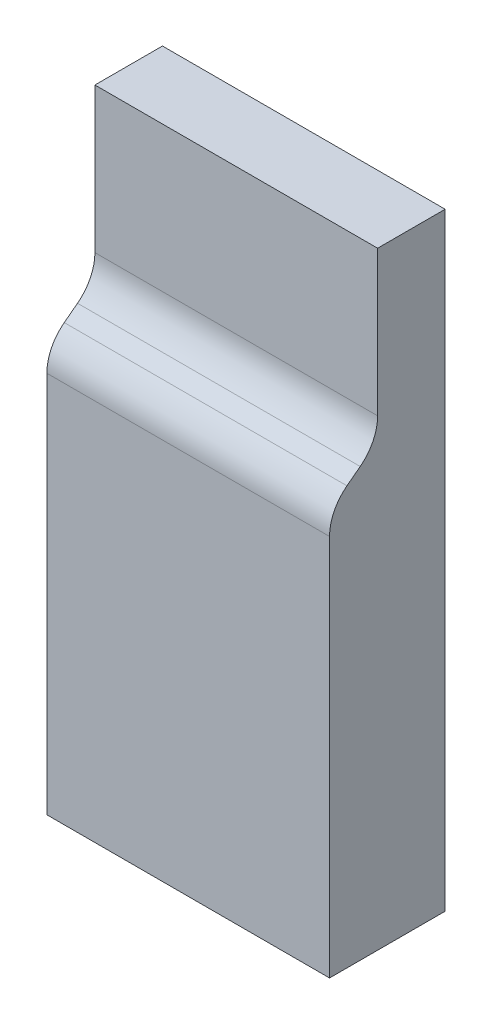
from build123d import *

# Parameters (mm, degrees)
SKETCH1_W           = 56.017642274
SKETCH1_H           = 120.476854835
BOSS_EXTRUDE1_DEPTH = 22.907839
CUT_EXTRUDE1_DEPTH  = 56.017642


with BuildPart() as part:
    # Sketch1 → Boss-Extrude1 (new body)
    with BuildSketch(Plane.XY):
        with Locations((-45.790278616, -5.132568266)):
            Rectangle(SKETCH1_W, SKETCH1_H)
    extrude(amount=BOSS_EXTRUDE1_DEPTH)

    # Sketch2 → Cut-Extrude1 (cut)
    with BuildSketch(Plane(origin=(-17.781457479, 0, 0), x_dir=(0, 0, -1), z_dir=(1, 0, 0))):
        with BuildLine():
            ThreePointArc((-16.831723704, 19.373649849), (-14.292248498, 22.454133795), (-13.382838726, 26.341458007))
            Line((-13.382838726, 26.341458007), (-13.382838726, 55.105859152))
            Line((-13.382838726, 55.105859152), (-22.907838726, 55.105859152))
            Line((-22.907838726, 55.105859152), (-22.907838726, 10.40214091))
            ThreePointArc((-22.907838726, 10.40214091), (-21.998428954, 14.289465122), (-19.458953748, 17.369949068))
            Line((-19.458953748, 17.369949068), (-16.831723704, 19.373649849))
        make_face()
    extrude(amount=-CUT_EXTRUDE1_DEPTH, mode=Mode.SUBTRACT)


solid = part.part
